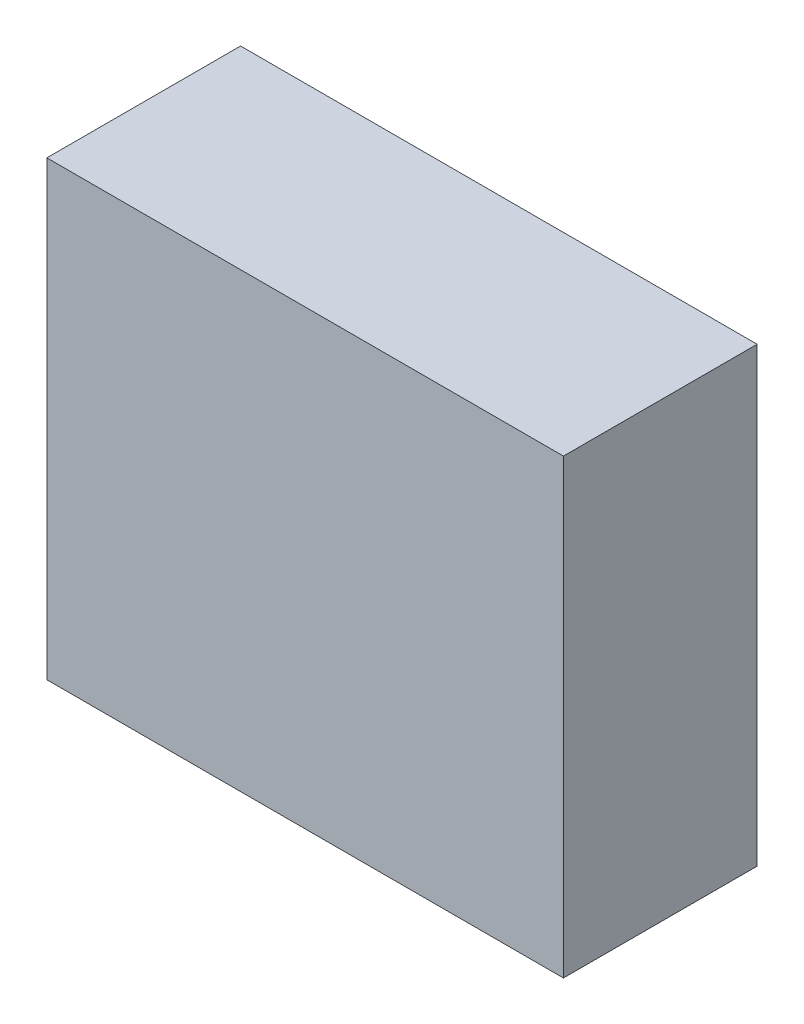
from build123d import *

# Parameters (mm, degrees)
BOSS_EXTRUDE1_DEPTH      = 19.05
BOSS_EXTRUDE1_DEPTH_BACK = 19.05
SKETCH1_W                = 101.6
SKETCH1_H                = 88.9


with BuildPart() as part:
    # Sketch1 → Boss-Extrude1 (new, two sides: drawn at the far end of the back side and taken through both)
    with BuildSketch(Plane.XY.offset(-BOSS_EXTRUDE1_DEPTH_BACK)):
        Rectangle(SKETCH1_W, SKETCH1_H)
    extrude(amount=BOSS_EXTRUDE1_DEPTH + BOSS_EXTRUDE1_DEPTH_BACK)


solid = part.part
